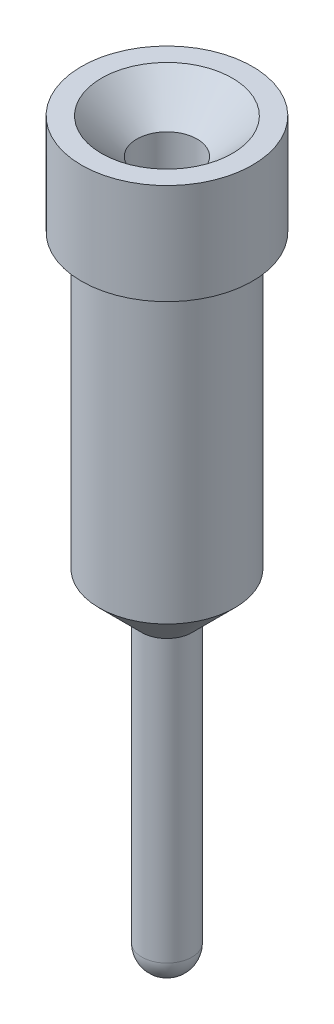
from build123d import *


with BuildPart() as part:
    # Sketch1 → Revolve1 (revolve)
    with BuildSketch(Plane.XY):
        with BuildLine():
            Line((-0.85, 0), (-0.85, -1))
            Line((-0.85, -1), (-0.675, -1))
            Line((-0.675, -1), (-0.675, -3.9))
            Line((-0.675, -3.9), (-0.25, -4.325))
            Line((-0.25, -4.325), (-0.25, -7.12))
            ThreePointArc((-0.25, -7.12), (-0.176776695, -7.296776695), (0, -7.37))
            Line((0, -7.37), (0, -4))
            Line((0, -4), (-0.3, -3.7))
            Line((-0.3, -3.7), (-0.3, -0.35))
            Line((-0.3, -0.35), (-0.65, 0))
            Line((-0.65, 0), (-0.85, 0))
        make_face()
    revolve(axis=Axis((0, 28.992562867, 0), (0, -1, 0)))


solid = part.part
